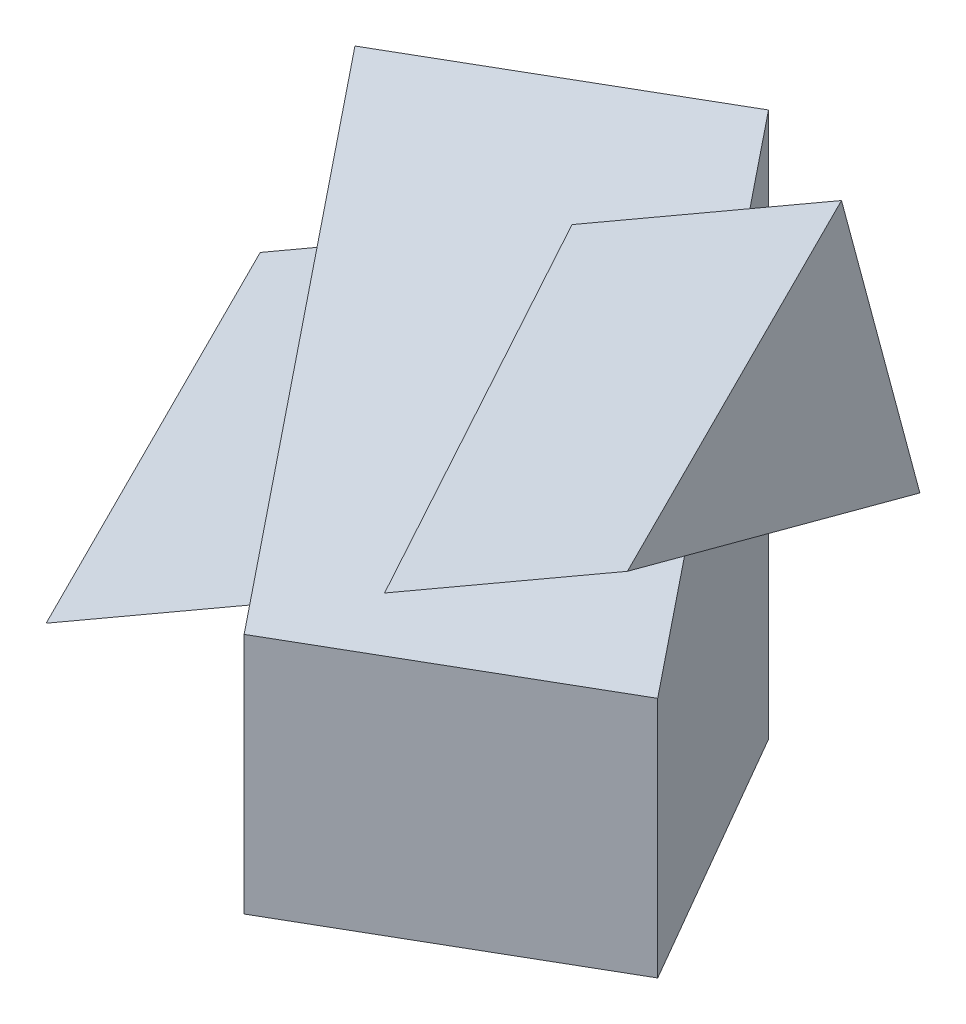
from build123d import *

# Parameters (mm, degrees)
SQUARE_PRISM_DEPTH        = 90
CUT_ON_SQUARE_PRISM_DEPTH = 72.650635095


with BuildPart() as part:
    # Sketch2 → square prism (new body)
    with BuildSketch(Plane(origin=(0, 0, 0), x_dir=(1, 0, 0), z_dir=(0, 1, 0))):
        Polygon((63.301270189, 0), (20, -25), (45, -68.301270189), (88.301270189, -43.301270189), align=None)
    extrude(amount=SQUARE_PRISM_DEPTH)

    # Sketch3 → Cut on square prism (cut, through all)
    with BuildSketch(Plane(origin=(4.174682453, 0, -2.410254038), x_dir=(0.5, 0, 0.866025404), z_dir=(-0.866025404, 0, 0.5))):
        Polygon((31.650635095, 90), (81.650635095, 90), (81.650635095, 40), align=None)
    extrude(amount=-CUT_ON_SQUARE_PRISM_DEPTH, mode=Mode.SUBTRACT)

    # Equilateral triangle prism: sweep along a path in path
    with BuildLine(Plane.XY.offset(56)) as equilateral_triangle_prism_path:
        Line((0, 12.940952255), (96, 68.366578097))
    # triangle → Equilateral triangle prism (sweep)
    with BuildSketch(Plane(origin=(0, 0, 0), x_dir=(0, 0, -1), z_dir=(1, 0, 0))):
        Polygon((-7.703708686, 0), (-20.644660941, 48.296291314), (-56, 12.940952255), align=None)
    sweep(path=equilateral_triangle_prism_path.line)


solid = part.part
